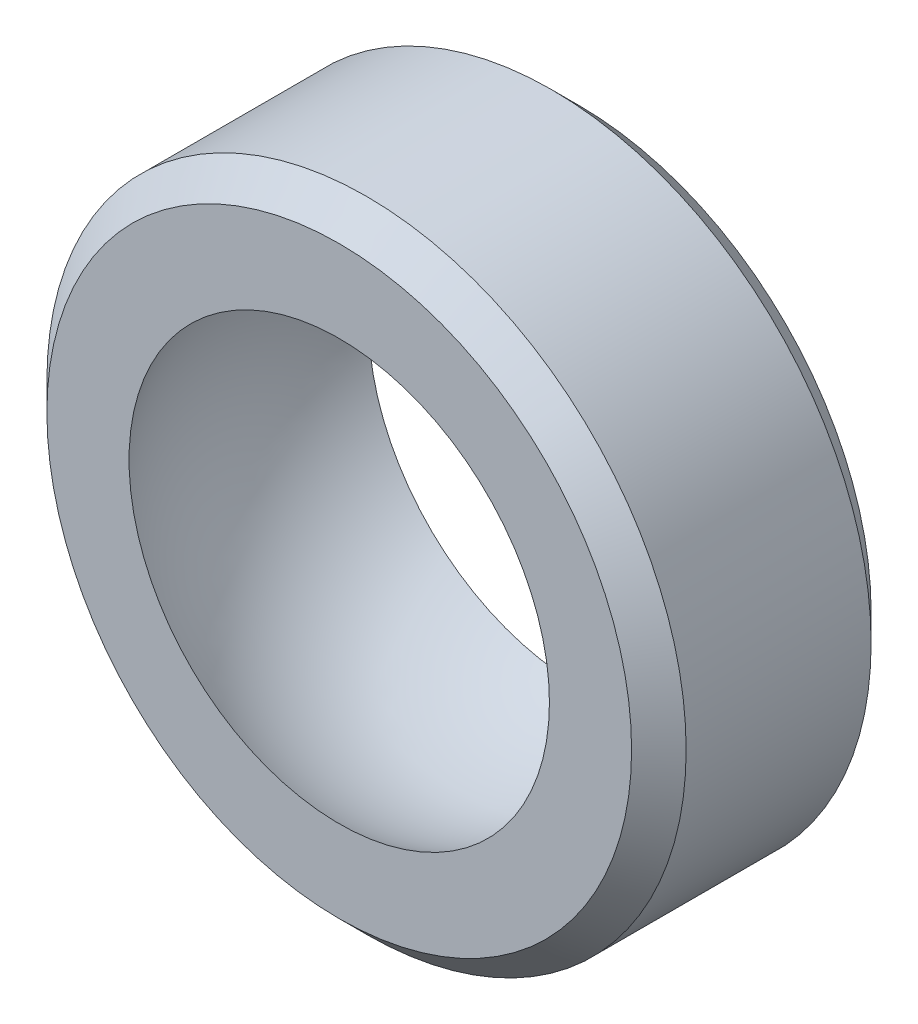
from build123d import *

# Parameters (mm, degrees)
SKETCH1_R      = 9.525
EXTRUDE1_DEPTH = 3.5687
CHAMFER1_SIZE  = 0.8128


with BuildPart() as part:
    # Sketch1 → Extrude1 (new, symmetric)
    with BuildSketch(Plane.XY):
        Circle(SKETCH1_R)
    extrude(amount=EXTRUDE1_DEPTH, both=True)

    # Sketch2 → Cut-Revolve1 (revolve, cut)
    with BuildSketch(Plane.XY):
        with BuildLine():
            Line((0, 7.208774), (0, -7.208774))
            ThreePointArc((0, -7.208774), (7.208774, 0), (0, 7.208774))
        make_face()
    revolve(axis=Axis((0, 7.208774, 0), (0, 1, 0)), mode=Mode.SUBTRACT)

    # Chamfer1
    chamfer1_edges = [part.edges().sort_by_distance(p)[0] for p in [
        (-9.525, 0, 3.5687),
        (-9.525, 0, -3.5687),
    ]]
    chamfer(chamfer1_edges, length=CHAMFER1_SIZE)


solid = part.part
